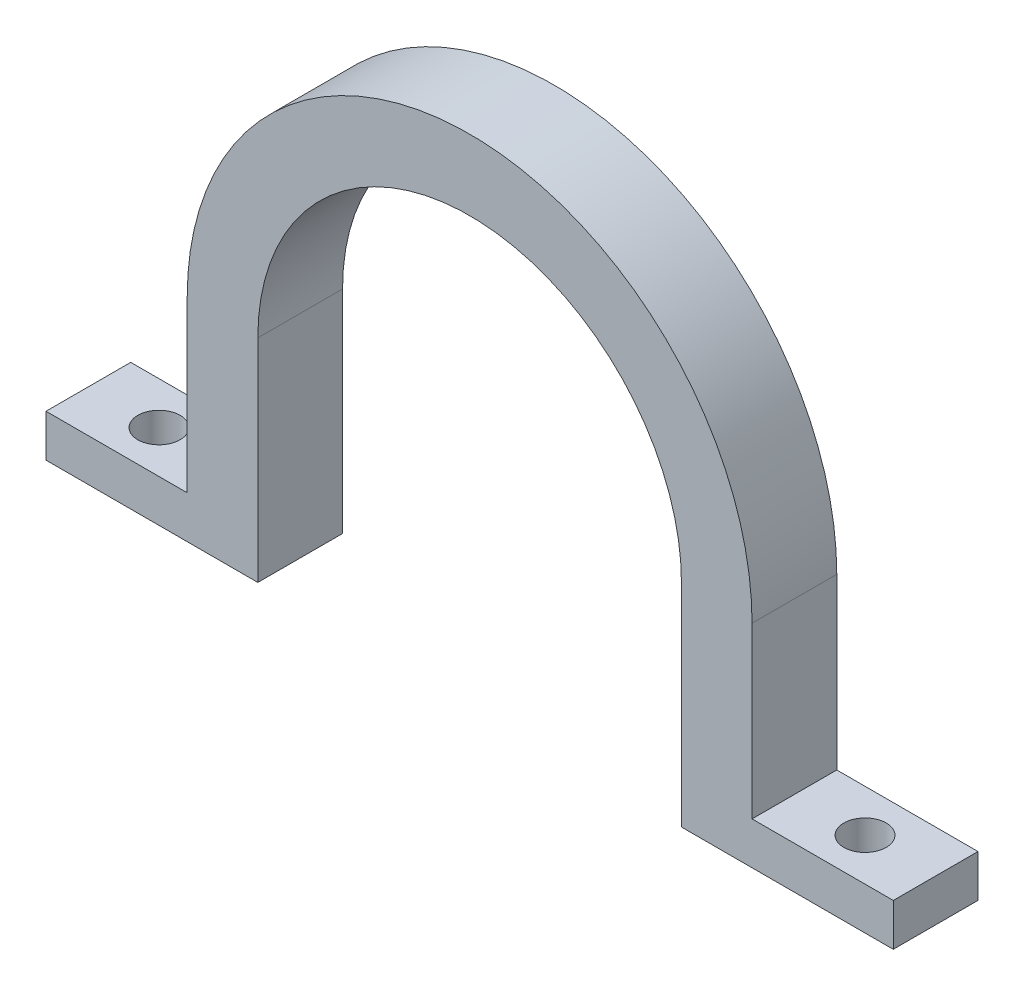
from build123d import *

# Parameters (mm, degrees)
BOSS_EXTRUDE1_DEPTH = 6
SKETCH2_R           = 1.5
CUT_EXTRUDE1_DEPTH  = 3


with BuildPart() as part:
    # Sketch1 → Boss-Extrude1 (new body)
    with BuildSketch(Plane.XY):
        with BuildLine():
            Line((15, 0), (15, -15))
            Line((15, -15), (30, -15))
            Line((30, -15), (30, -12))
            Line((30, -12), (20, -12))
            Line((20, -12), (20, 0))
            ThreePointArc((20, 0), (0, 20), (-20, 0))
            Line((-20, 0), (-20, -12))
            Line((-20, -12), (-30, -12))
            Line((-30, -12), (-30, -15))
            Line((-30, -15), (-15, -15))
            Line((-15, -15), (-15, 0))
            ThreePointArc((-15, 0), (0, 15), (15, 0))
        make_face()
    extrude(amount=BOSS_EXTRUDE1_DEPTH)

    # Sketch2 → Cut-Extrude1 (cut)
    with BuildSketch(Plane(origin=(0, -12, 0), x_dir=(1, 0, 0), z_dir=(0, 1, 0))):
        with Locations((-25, -3)):
            Circle(SKETCH2_R)
        with Locations((25, -3)):
            Circle(SKETCH2_R)
    extrude(amount=-CUT_EXTRUDE1_DEPTH, mode=Mode.SUBTRACT)


solid = part.part
